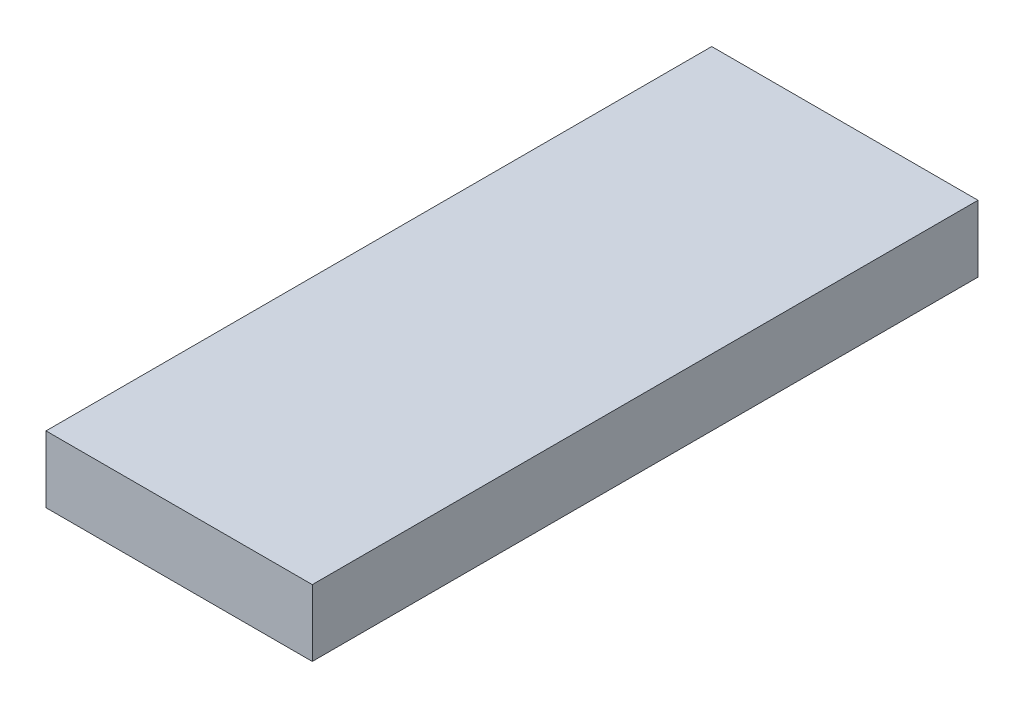
from build123d import *

# Parameters (mm, degrees)
SKETCH1_W           = 20
SKETCH1_H           = 50
BOSS_EXTRUDE1_DEPTH = 5


with BuildPart() as part:
    # Sketch1 → Boss-Extrude1 (new body)
    with BuildSketch(Plane(origin=(0, 0, 0), x_dir=(1, 0, 0), z_dir=(0, 1, 0))):
        with Locations((10, 25)):
            Rectangle(SKETCH1_W, SKETCH1_H)
    extrude(amount=BOSS_EXTRUDE1_DEPTH)


solid = part.part
